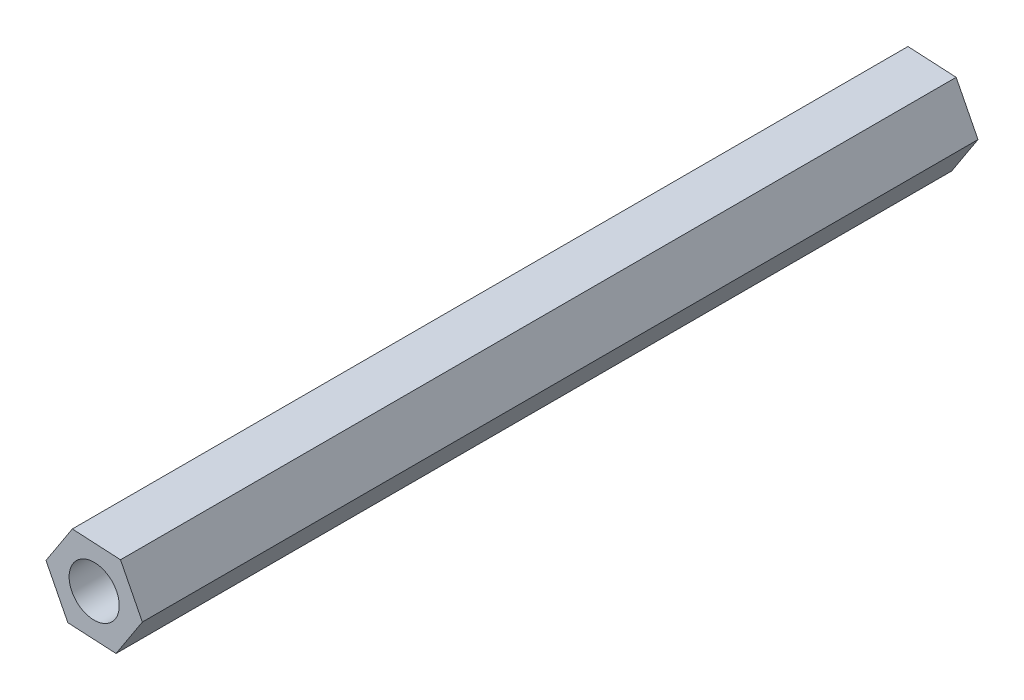
from build123d import *

# Parameters (mm, degrees)
BOSS_EXTRUDE1_DEPTH = 50
SKETCH2_R           = 1.5
CUT_EXTRUDE1_DEPTH  = 51


with BuildPart() as part:
    # Sketch1 → Boss-Extrude1 (new body)
    with BuildSketch(Plane.XY):
        Polygon((1.57545706, 2.418939517), (-1.307134542, 2.573855595), (-2.882591602, 0.154916078), (-1.57545706, -2.418939517), (1.307134542, -2.573855595), (2.882591602, -0.154916078), align=None)
    extrude(amount=BOSS_EXTRUDE1_DEPTH)

    # Sketch2 → Cut-Extrude1 (cut, through all)
    with BuildSketch(Plane(origin=(0, 0, 0), x_dir=(-1, 0, 0), z_dir=(0, 0, -1))):
        Circle(SKETCH2_R)
    extrude(amount=-CUT_EXTRUDE1_DEPTH, mode=Mode.SUBTRACT)


solid = part.part
